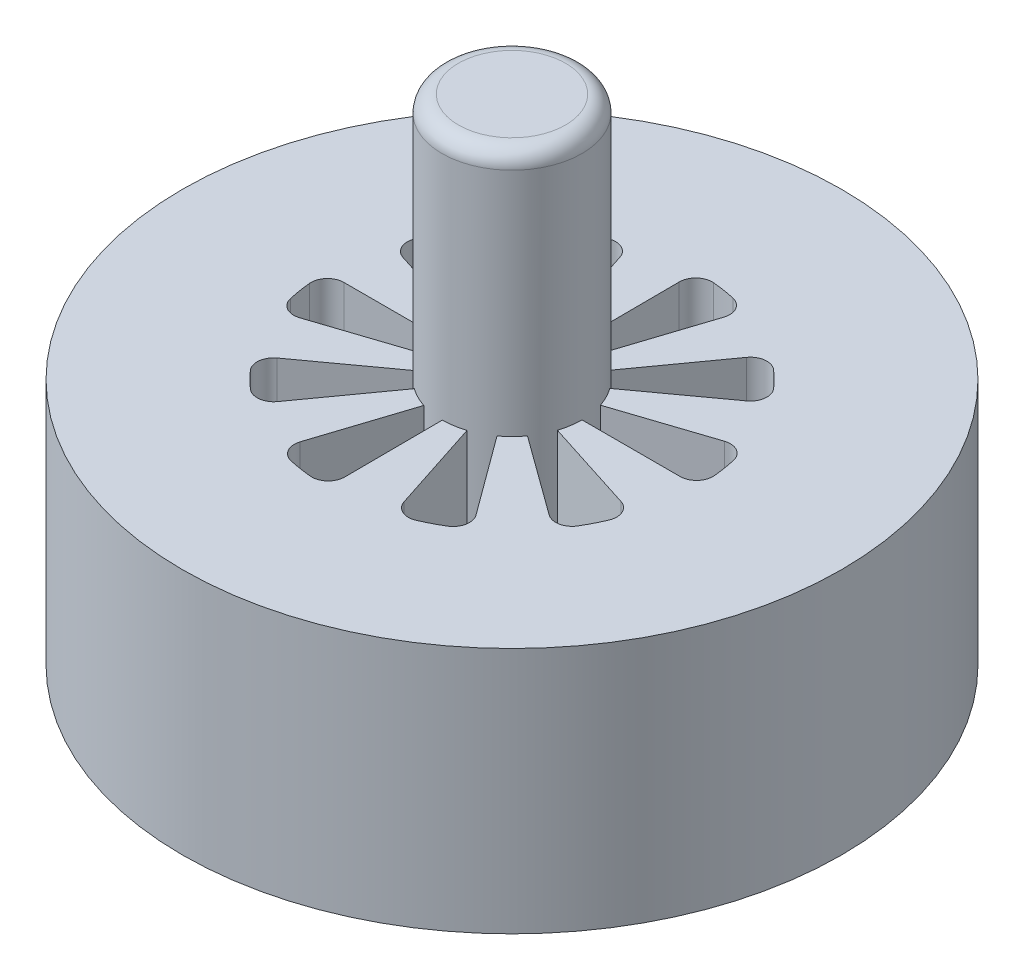
from build123d import *

# Parameters (mm, degrees)
SKETCH1_R           = 101.6
BOSS_EXTRUDE1_DEPTH = 76.2
SKETCH2_R           = 21.59
BOSS_EXTRUDE2_DEPTH = 76.2
FILLET1_R           = 5.08


with BuildPart() as part:
    # Sketch1 → Boss-Extrude1 (new body)
    with BuildSketch(Plane(origin=(0, 0, 0), x_dir=(1, 0, 0), z_dir=(0, 1, 0))):
        Circle(SKETCH1_R)
        with BuildLine():
            Line((21.59, 0), (51.821602638, 0))
            ThreePointArc((51.821602638, 0), (55.584852402, 1.667617955), (56.877368749, 5.575609756))
            ThreePointArc((56.877368749, 5.575609756), (56.423832827, 9.081497074), (55.75440626, 12.552636482))
            ThreePointArc((55.75440626, 12.552636482), (53.300937227, 15.857706546), (49.204484901, 16.260294142))
            Line((49.204484901, 16.260294142), (20.499652171, 6.774390074))
            ThreePointArc((20.499652171, 6.774390074), (21.315670179, 3.430787784), (21.59, 0))
        make_face(mode=Mode.SUBTRACT)
        with BuildLine():
            Line((20.566453564, -6.568796527), (49.364825579, -15.766816277))
            ThreePointArc((49.364825579, -15.766816277), (52.442290076, -18.500350747), (52.484516777, -22.616321511))
            ThreePointArc((52.484516777, -22.616321511), (50.985809694, -25.818011346), (49.292019101, -28.920915493))
            ThreePointArc((49.292019101, -28.920915493), (45.949291463, -31.322825227), (41.92455721, -30.459973781))
            Line((41.92455721, -30.459973781), (17.466676909, -12.690283597))
            ThreePointArc((17.466676909, -12.690283597), (19.261305884, -9.753470953), (20.566453564, -6.568796527))
        make_face(mode=Mode.SUBTRACT)
        with BuildLine():
            Line((12.777568723, -17.402926119), (30.669480735, -41.771538773))
            ThreePointArc((30.669480735, -41.771538773), (31.552470563, -45.791902859), (29.167325768, -49.146613388))
            ThreePointArc((29.167325768, -49.146613388), (26.072940201, -50.855916954), (22.87879353, -52.37063401))
            ThreePointArc((22.87879353, -52.37063401), (18.762662945, -52.349013795), (16.013755891, -49.285272874))
            Line((16.013755891, -49.285272874), (6.671676909, -20.533310187))
            ThreePointArc((6.671676909, -20.533310187), (9.849777409, -19.212235294), (12.777568723, -17.402926119))
        make_face(mode=Mode.SUBTRACT)
        with BuildLine():
            Line((0.108086924, -21.589729438), (0.259436667, -51.82095322))
            ThreePointArc((0.259436667, -51.82095322), (-1.389320275, -55.592504489), (-5.290792323, -56.904569382))
            ThreePointArc((-5.290792323, -56.904569382), (-8.798906261, -56.468590815), (-12.273353548, -55.816550347))
            ThreePointArc((-12.273353548, -55.816550347), (-15.590665099, -53.379658372), (-16.013755891, -49.285272874))
            Line((-16.013755891, -49.285272874), (-6.671676909, -20.533310187))
            ThreePointArc((-6.671676909, -20.533310187), (-3.324031254, -21.332578752), (0.108086924, -21.589729438))
        make_face(mode=Mode.SUBTRACT)
        with BuildLine():
            Line((-12.602680406, -17.52998992), (-30.24970339, -42.076524866))
            ThreePointArc((-30.24970339, -42.076524866), (-33.800437989, -44.158658923), (-37.728007574, -42.926913988))
            ThreePointArc((-37.728007574, -42.926913988), (-40.309869596, -40.512182281), (-42.737496726, -37.942441587))
            ThreePointArc((-42.737496726, -37.942441587), (-43.988888982, -34.021087758), (-41.92455721, -30.459973781))
            Line((-41.92455721, -30.459973781), (-17.466676909, -12.690283597))
            ThreePointArc((-17.466676909, -12.690283597), (-15.228172958, -15.304602195), (-12.602680406, -17.52998992))
        make_face(mode=Mode.SUBTRACT)
        with BuildLine():
            Line((-20.499652171, -6.774390074), (-49.204484901, -16.260294142))
            ThreePointArc((-49.204484901, -16.260294142), (-53.300937227, -15.857706546), (-55.75440626, -12.552636482))
            ThreePointArc((-55.75440626, -12.552636482), (-56.423832827, -9.081497074), (-56.877368749, -5.575609756))
            ThreePointArc((-56.877368749, -5.575609756), (-55.584852402, -1.667617955), (-51.821602638, 0))
            Line((-51.821602638, 0), (-21.59, 0))
            ThreePointArc((-21.59, 0), (-21.315670179, -3.430787784), (-20.499652171, -6.774390074))
        make_face(mode=Mode.SUBTRACT)
        with BuildLine():
            Line((-20.566453564, 6.568796527), (-49.364825579, 15.766816277))
            ThreePointArc((-49.364825579, 15.766816277), (-52.442290076, 18.500350747), (-52.484516777, 22.616321511))
            ThreePointArc((-52.484516777, 22.616321511), (-50.985809694, 25.818011346), (-49.292019101, 28.920915493))
            ThreePointArc((-49.292019101, 28.920915493), (-45.949291463, 31.322825227), (-41.92455721, 30.459973781))
            Line((-41.92455721, 30.459973781), (-17.466676909, 12.690283597))
            ThreePointArc((-17.466676909, 12.690283597), (-19.261305884, 9.753470953), (-20.566453564, 6.568796527))
        make_face(mode=Mode.SUBTRACT)
        with BuildLine():
            Line((-12.777568723, 17.402926119), (-30.669480735, 41.771538773))
            ThreePointArc((-30.669480735, 41.771538773), (-31.552470563, 45.791902859), (-29.167325768, 49.146613388))
            ThreePointArc((-29.167325768, 49.146613388), (-26.072940201, 50.855916954), (-22.87879353, 52.37063401))
            ThreePointArc((-22.87879353, 52.37063401), (-18.762662945, 52.349013795), (-16.013755891, 49.285272874))
            Line((-16.013755891, 49.285272874), (-6.671676909, 20.533310187))
            ThreePointArc((-6.671676909, 20.533310187), (-9.849777409, 19.212235294), (-12.777568723, 17.402926119))
        make_face(mode=Mode.SUBTRACT)
        with BuildLine():
            Line((-0.108086924, 21.589729438), (-0.259436667, 51.82095322))
            ThreePointArc((-0.259436667, 51.82095322), (1.389320275, 55.592504489), (5.290792323, 56.904569382))
            ThreePointArc((5.290792323, 56.904569382), (8.798906261, 56.468590815), (12.273353548, 55.816550347))
            ThreePointArc((12.273353548, 55.816550347), (15.590665099, 53.379658372), (16.013755891, 49.285272874))
            Line((16.013755891, 49.285272874), (6.671676909, 20.533310187))
            ThreePointArc((6.671676909, 20.533310187), (3.324031254, 21.332578752), (-0.108086924, 21.589729438))
        make_face(mode=Mode.SUBTRACT)
        with BuildLine():
            Line((12.602680406, 17.52998992), (30.24970339, 42.076524866))
            ThreePointArc((30.24970339, 42.076524866), (33.800437989, 44.158658923), (37.728007574, 42.926913988))
            ThreePointArc((37.728007574, 42.926913988), (40.309869596, 40.512182281), (42.737496726, 37.942441587))
            ThreePointArc((42.737496726, 37.942441587), (43.988888982, 34.021087758), (41.92455721, 30.459973781))
            Line((41.92455721, 30.459973781), (17.466676909, 12.690283597))
            ThreePointArc((17.466676909, 12.690283597), (15.228172958, 15.304602195), (12.602680406, 17.52998992))
        make_face(mode=Mode.SUBTRACT)
    extrude(amount=BOSS_EXTRUDE1_DEPTH)

    # Sketch2 → Boss-Extrude2 (add)
    with BuildSketch(Plane(origin=(0, 76.2, 0), x_dir=(1, 0, 0), z_dir=(0, 1, 0))):
        Circle(SKETCH2_R)
    extrude(amount=BOSS_EXTRUDE2_DEPTH)

    # Fillet1
    fillet1_edges = [part.edges().sort_by_distance(p)[0] for p in [
        (-21.59, 152.4, 0),
    ]]
    fillet(fillet1_edges, radius=FILLET1_R)


solid = part.part
